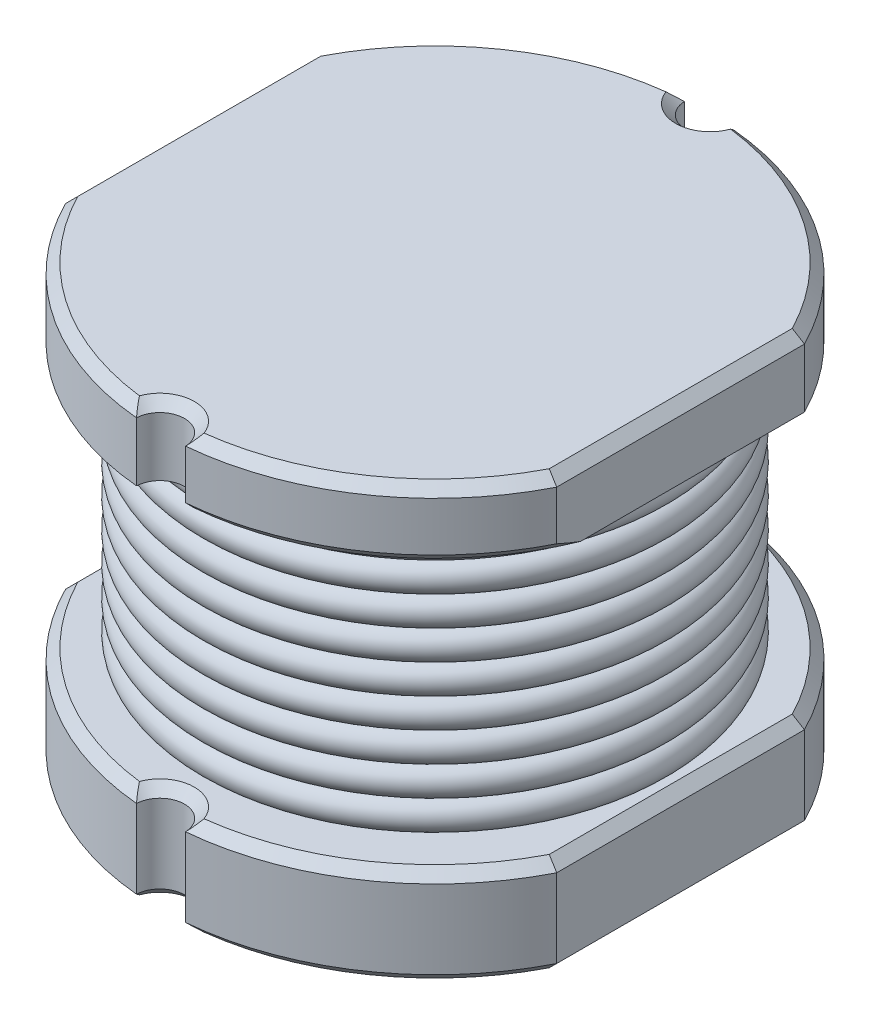
from build123d import *

# Parameters (mm, degrees)
SKETCH1_R                 = 2.8
BASE_DEPTH                = 1
SKETCH2_R                 = 2
COIL_ENCOMPASSMENT_DEPTH  = 2.7
SKETCH3_R                 = 2.8
TOP_BASE_DEPTH            = 0.7
SKETCH5_R                 = 0.25
SIDE_CUTS_FOR_BASES_DEPTH = 4.4
SKETCH98_W                = 0.3
SKETCH98_H                = 2.521904042
BASE_SIDES_DEPTH          = 5.4
COIL_PROFILE_R            = 0.15
COIL_P_COUNT              = 10
COIL_P_PITCH              = 0.3
BASES_C_SIZE              = 0.1


with BuildPart() as part:
    # Sketch1 → BASE (new body)
    with BuildSketch(Plane(origin=(0, 0, 0), x_dir=(1, 0, 0), z_dir=(0, 1, 0))):
        Circle(SKETCH1_R)
    extrude(amount=BASE_DEPTH)

    # Sketch2 → COIL ENCOMPASSMENT (add)
    with BuildSketch(Plane(origin=(0, 1, 0), x_dir=(1, 0, 0), z_dir=(0, 1, 0))):
        Circle(SKETCH2_R)
    extrude(amount=COIL_ENCOMPASSMENT_DEPTH)

    # Sketch3 → TOP BASE (add)
    with BuildSketch(Plane(origin=(0, 3.7, 0), x_dir=(1, 0, 0), z_dir=(0, 1, 0))):
        Circle(SKETCH3_R)
    extrude(amount=TOP_BASE_DEPTH)

    # Sketch5 → SIDE CUTS FOR BASES (cut)
    with BuildSketch(Plane(origin=(0, 4.4, 0), x_dir=(1, 0, 0), z_dir=(0, 1, 0))):
        with Locations((0, -2.8)):
            Circle(SKETCH5_R)
        with Locations((0, 2.8)):
            Circle(SKETCH5_R)
    extrude(amount=-SIDE_CUTS_FOR_BASES_DEPTH, mode=Mode.SUBTRACT)

    # Sketch98 → BASE SIDES (cut, through all)
    with BuildSketch(Plane(origin=(0, 4.4, 0), x_dir=(1, 0, 0), z_dir=(0, 1, 0))):
        with Locations((-2.65, 0)):
            Rectangle(SKETCH98_W, SKETCH98_H)
    base_sides = extrude(amount=-BASE_SIDES_DEPTH, mode=Mode.SUBTRACT)

    # BS M: BASE SIDES across plane
    add(base_sides.mirror(Plane(origin=(0, 0, 0), x_dir=(0, 0, 1), z_dir=(1, 0, 0))), mode=Mode.SUBTRACT)

    # BASES C
    bases_c_edges = [part.edges().sort_by_distance(p)[0] for p in [
        (1.572861143, 0, 2.316486095),
        (0, 0, 2.55),
        (0, 4.4, 2.55),
        (0, 1, 2.55),
        (-1.572861143, 3.7, -2.316486095),
        (-1.572861143, 4.4, -2.316486095),
        (-1.572861143, 0, -2.316486095),
        (-1.572861143, 1, -2.316486095),
        (0, 0, -2.55),
        (0, 4.4, -2.55),
        (0, 1, -2.55),
        (1.572861143, 1, 2.316486095),
        (-1.572861143, 4.4, 2.316486095),
        (-1.572861143, 0, 2.316486095),
        (-1.572861143, 1, 2.316486095),
        (-2.5, 4.4, 0),
        (-2.5, 1, 0),
        (-2.5, 0, 0),
        (-2, 1, 0),
        (1.572861143, 4.4, -2.316486095),
        (1.572861143, 0, -2.316486095),
        (1.572861143, 1, -2.316486095),
        (2.5, 0, 0),
        (2.5, 4.4, 0),
        (2.5, 1, 0),
        (1.572861143, 3.7, 2.316486095),
        (1.572861143, 4.4, 2.316486095),
    ]]
    chamfer(bases_c_edges, length=BASES_C_SIZE)


with BuildPart() as body_2:
    # COIL: sweep along a path in Sketch6
    with BuildLine(Plane(origin=(0, 1.15, 0), x_dir=(1, 0, 0), z_dir=(0, 1, 0))) as coil_path:
        CenterArc((0, 0), 2.25, 0, 360)
    # COIL profile (on start of the path) → COIL (sweep)
    with BuildSketch(Plane(origin=(2.25, 1.15, 0), x_dir=(-1, 0, 0), z_dir=(0, 0, -1))):
        Circle(COIL_PROFILE_R)
    sweep(path=coil_path.line)


with BuildPart() as coil_p_1:
    # COIL P: pattern copy
    add(body_2.part.moved(Location(Vector(0, 1, 0) * (1 * COIL_P_PITCH))))


with BuildPart() as coil_p_2:
    # COIL P: pattern copy
    add(body_2.part.moved(Location(Vector(0, 1, 0) * (2 * COIL_P_PITCH))))


with BuildPart() as coil_p_3:
    # COIL P: pattern copy
    add(body_2.part.moved(Location(Vector(0, 1, 0) * (3 * COIL_P_PITCH))))


with BuildPart() as coil_p_4:
    # COIL P: pattern copy
    add(body_2.part.moved(Location(Vector(0, 1, 0) * (4 * COIL_P_PITCH))))


with BuildPart() as coil_p_5:
    # COIL P: pattern copy
    add(body_2.part.moved(Location(Vector(0, 1, 0) * (5 * COIL_P_PITCH))))


with BuildPart() as coil_p_6:
    # COIL P: pattern copy
    add(body_2.part.moved(Location(Vector(0, 1, 0) * (6 * COIL_P_PITCH))))


with BuildPart() as coil_p_7:
    # COIL P: pattern copy
    add(body_2.part.moved(Location(Vector(0, 1, 0) * (7 * COIL_P_PITCH))))


with BuildPart() as coil_p_8:
    # COIL P: pattern copy
    add(body_2.part.moved(Location(Vector(0, 1, 0) * (8 * COIL_P_PITCH))))


with BuildPart() as coil_p_9:
    # COIL P: pattern copy
    add(body_2.part.moved(Location(Vector(0, 1, 0) * (9 * COIL_P_PITCH))))


solid = Compound([part.part, body_2.part, coil_p_1.part, coil_p_2.part, coil_p_3.part, coil_p_4.part, coil_p_5.part, coil_p_6.part, coil_p_7.part, coil_p_8.part, coil_p_9.part])
